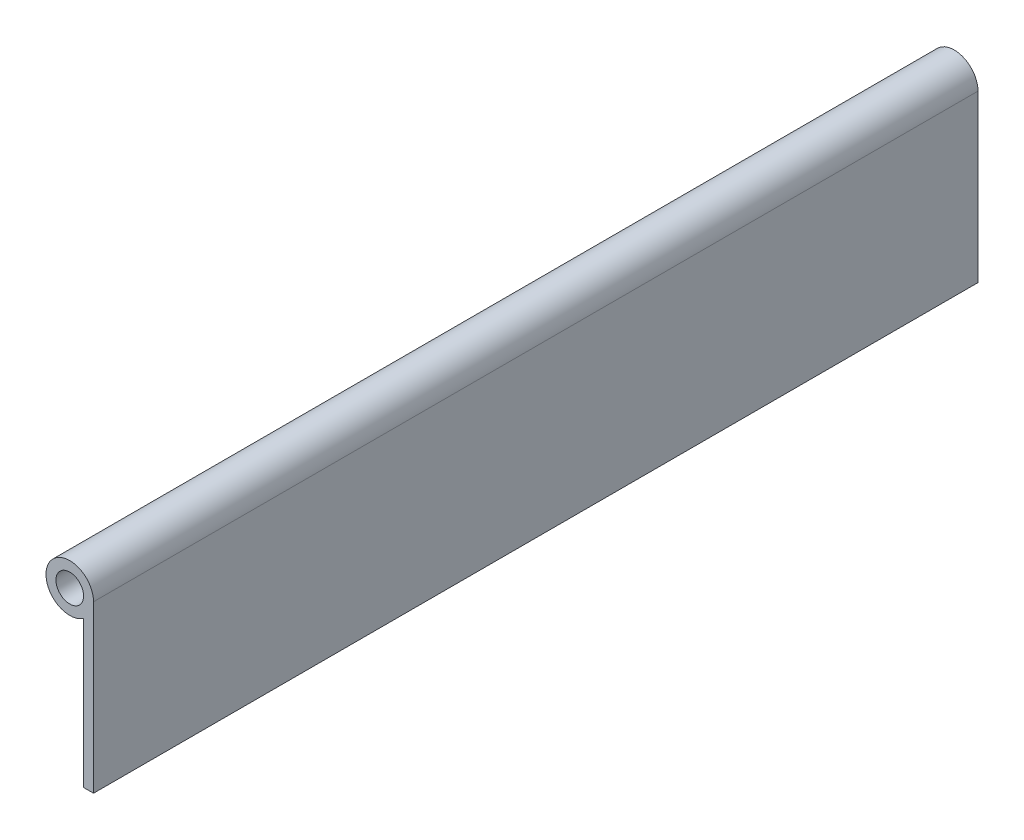
from build123d import *

# Parameters (mm, degrees)
SKETCH1_R           = 3.175
BOSS_EXTRUDE1_DEPTH = 203.2


with BuildPart() as part:
    # Sketch1 → Boss-Extrude1 (new body)
    with BuildSketch(Plane.XY):
        with BuildLine():
            Line((5.461, 0), (5.461, -38.1))
            Line((5.461, -38.1), (3.175, -38.1))
            Line((3.175, -38.1), (3.175, -4.443185344))
            ThreePointArc((3.175, -4.443185344), (-4.855985791, 2.498384078), (5.461, 0))
        make_face()
        Circle(SKETCH1_R, mode=Mode.SUBTRACT)
    extrude(amount=BOSS_EXTRUDE1_DEPTH)


solid = part.part
